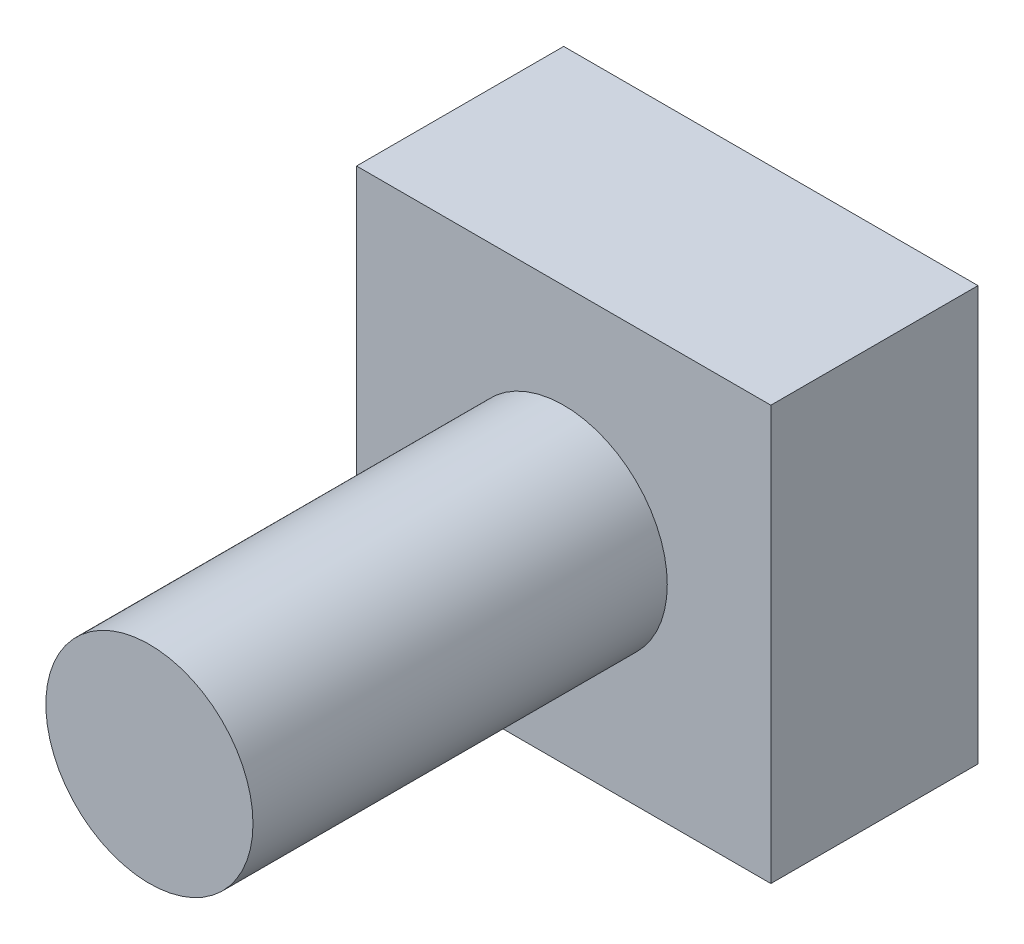
from build123d import *

# Parameters (mm, degrees)
SKETCH2_W           = 12.7
SKETCH2_H           = 12.7
BOSS_EXTRUDE1_DEPTH = 6.35
SKETCH3_R           = 3.175
BOSS_EXTRUDE2_DEPTH = 12.7


with BuildPart() as part:
    # Sketch2 → Boss-Extrude1 (new body)
    with BuildSketch(Plane.XY):
        with Locations((6.35, 6.35)):
            Rectangle(SKETCH2_W, SKETCH2_H)
    extrude(amount=BOSS_EXTRUDE1_DEPTH)

    # Sketch3 → Boss-Extrude2 (add)
    with BuildSketch(Plane.XY.offset(6.35)):
        with Locations((6.35, 6.35)):
            Circle(SKETCH3_R)
    extrude(amount=BOSS_EXTRUDE2_DEPTH)


solid = part.part
